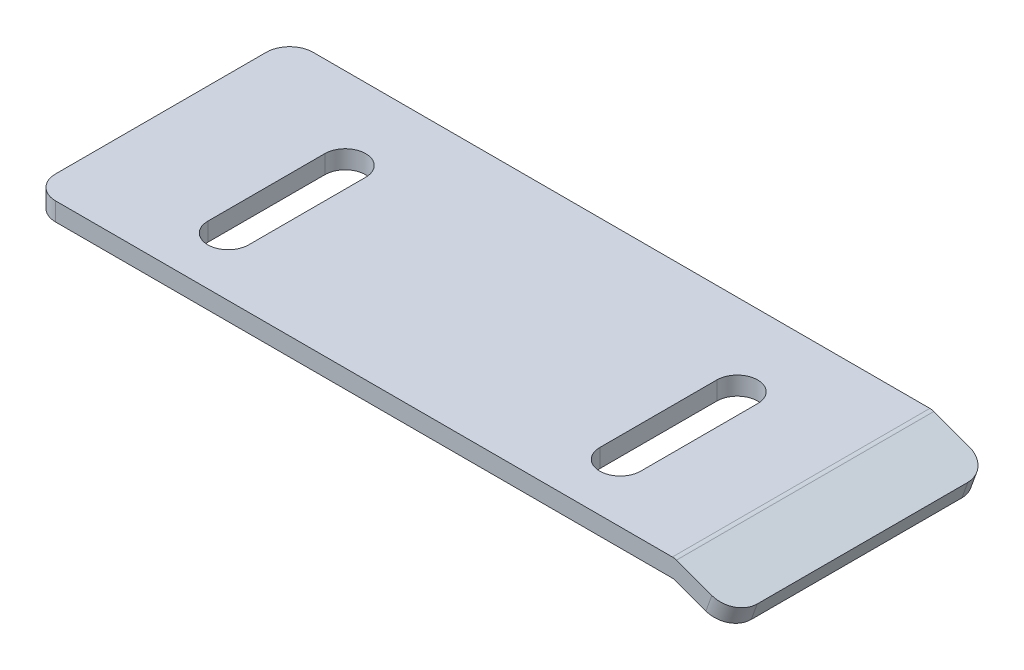
from build123d import *

# Parameters (mm, degrees)
BOSS_EXTRUDE1_DEPTH = 22
FILLET1_R           = 1
FILLET2_R           = 2
CUT_EXTRUDE1_DEPTH  = 4.256447705


with BuildPart() as part:
    # Sketch1 → Boss-Extrude1 (new body)
    with BuildSketch(Plane.XY):
        Polygon((-37.577345781, 8.579229267), (17.308314067, 8.579229267), (22.382654219, 6.732320493), (21.869624004, 5.322781562), (17.222654219, 7.014140243), (-37.577345781, 7.014140243), align=None)
    extrude(amount=BOSS_EXTRUDE1_DEPTH)

    # Fillet1
    fillet1_edges = [part.edges().sort_by_distance(p)[0] for p in [
        (17.308314067, 8.579229267, 11),
    ]]
    fillet(fillet1_edges, radius=FILLET1_R)

    # Fillet2
    fillet2_edges = [part.edges().sort_by_distance(p)[0] for p in [
        (22.126139112, 6.027551028, 22),
        (-37.577345781, 7.796684755, 22),
        (22.126139112, 6.027551028, 0),
        (-37.577345781, 7.796684755, 0),
    ]]
    fillet(fillet2_edges, radius=FILLET2_R)

    # Sketch3 → Cut-Extrude1 (cut, through all)
    with BuildSketch(Plane(origin=(0, 8.579229267, 0), x_dir=(1, 0, 0), z_dir=(0, 1, 0))):
        with BuildLine():
            Line((-24.077345781, -17), (-24.077345781, -7))
            ThreePointArc((-24.077345781, -7), (-25.827345781, -5.25), (-27.577345781, -7))
            Line((-27.577345781, -7), (-27.577345781, -17))
            ThreePointArc((-27.577345781, -17), (-25.827345781, -18.75), (-24.077345781, -17))
        make_face()
        with BuildLine():
            Line((9.422654219, -17), (9.422654219, -7))
            ThreePointArc((9.422654219, -7), (7.672654219, -5.25), (5.922654219, -7))
            Line((5.922654219, -7), (5.922654219, -17))
            ThreePointArc((5.922654219, -17), (7.672654219, -18.75), (9.422654219, -17))
        make_face()
    extrude(amount=-CUT_EXTRUDE1_DEPTH, mode=Mode.SUBTRACT)


solid = part.part
